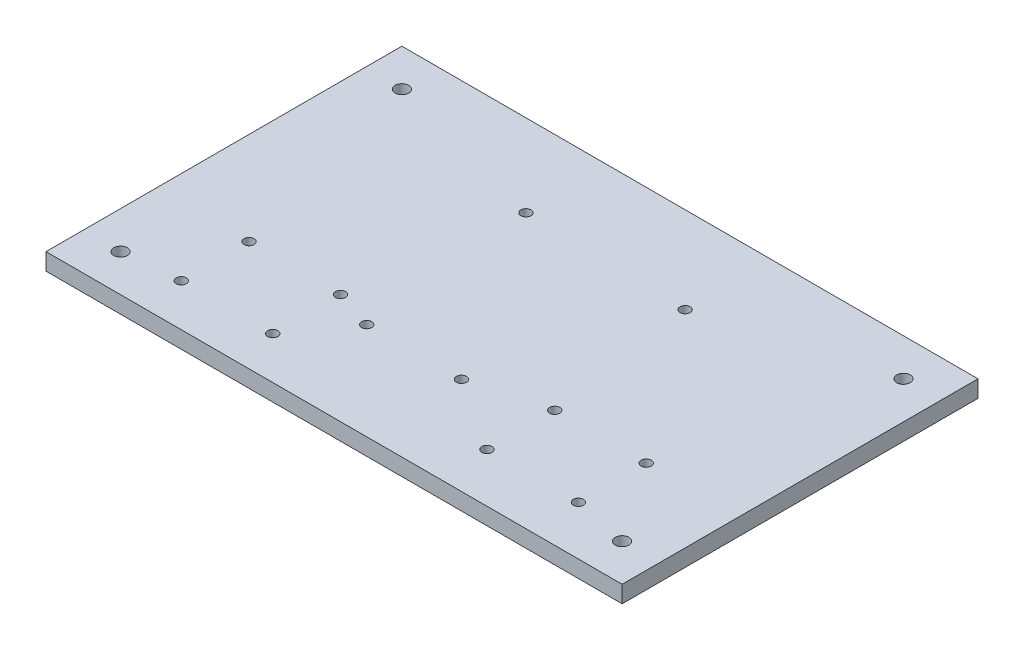
from build123d import *

# Parameters (mm, degrees)
SKETCH_1_W      = 170
SKETCH_1_H      = 105
SKETCH_1_R      = 2
SKETCH_1_R_2    = 1.5
EXTRUDE_1_DEPTH = 5


with BuildPart() as part:
    # ｽｹｯﾁ1 → ﾎﾞｽ - 押し出し1 (new body)
    with BuildSketch(Plane(origin=(0, 0, 0), x_dir=(1, 0, 0), z_dir=(0, 1, 0))):
        with Locations((85, 52.5)):
            Rectangle(SKETCH_1_W, SKETCH_1_H)
        with Locations((11, 94)):
            Circle(SKETCH_1_R, mode=Mode.SUBTRACT)
        with Locations((11, 11)):
            Circle(SKETCH_1_R, mode=Mode.SUBTRACT)
        with Locations((159, 11)):
            Circle(SKETCH_1_R, mode=Mode.SUBTRACT)
        with Locations((159, 94)):
            Circle(SKETCH_1_R, mode=Mode.SUBTRACT)
        with Locations((54.4, 12.5)):
            Circle(SKETCH_1_R_2, mode=Mode.SUBTRACT)
        with Locations((27.4, 12.5)):
            Circle(SKETCH_1_R_2, mode=Mode.SUBTRACT)
        with Locations((54.4, 32.5)):
            Circle(SKETCH_1_R_2, mode=Mode.SUBTRACT)
        with Locations((27.4, 32.5)):
            Circle(SKETCH_1_R_2, mode=Mode.SUBTRACT)
        with Locations((60.88, 80.73)):
            Circle(SKETCH_1_R_2, mode=Mode.SUBTRACT)
        with Locations((65.97, 28.66)):
            Circle(SKETCH_1_R_2, mode=Mode.SUBTRACT)
        with Locations((93.92, 28.66)):
            Circle(SKETCH_1_R_2, mode=Mode.SUBTRACT)
        with Locations((109.12, 79.45)):
            Circle(SKETCH_1_R_2, mode=Mode.SUBTRACT)
        with Locations((115.6, 34.5)):
            Circle(SKETCH_1_R_2, mode=Mode.SUBTRACT)
        with Locations((142.6, 34.5)):
            Circle(SKETCH_1_R_2, mode=Mode.SUBTRACT)
        with Locations((142.6, 14.5)):
            Circle(SKETCH_1_R_2, mode=Mode.SUBTRACT)
        with Locations((115.6, 14.5)):
            Circle(SKETCH_1_R_2, mode=Mode.SUBTRACT)
    extrude(amount=EXTRUDE_1_DEPTH)


solid = part.part
